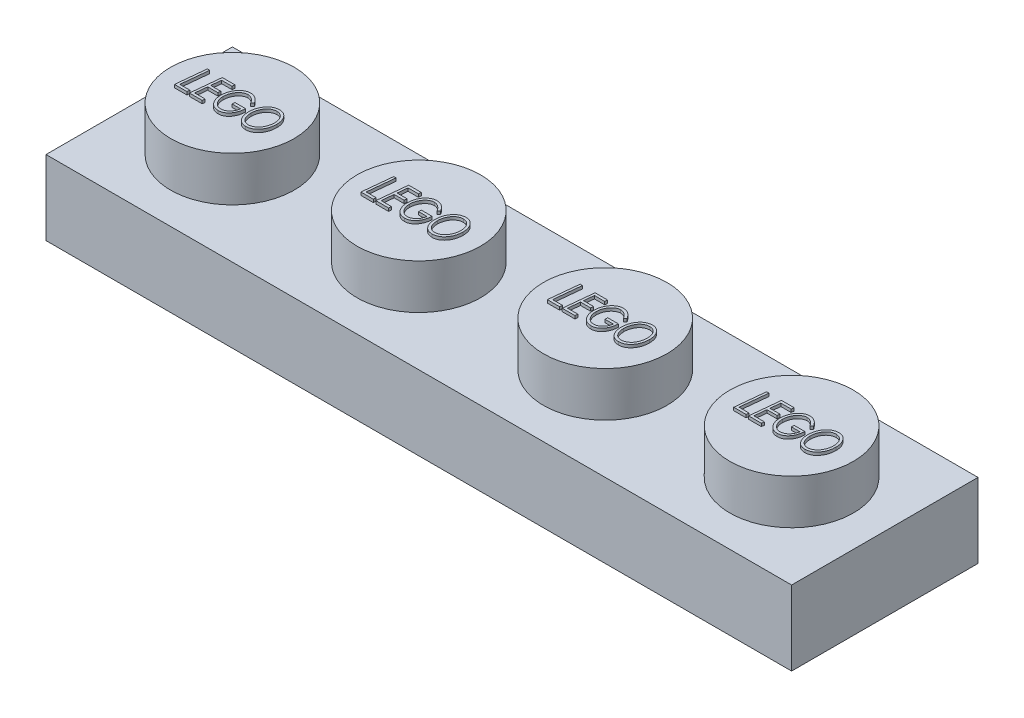
from build123d import *

# Parameters (mm, degrees)
SKETCH2_W           = 31.75
SKETCH2_H           = 7.9375
BOSS_EXTRUDE3_DEPTH = 3.175
SKETCH3_R           = 2.630752939
BOSS_EXTRUDE4_DEPTH = 1.905
LPATTERN1_COUNT     = 4
LPATTERN1_PITCH     = 7.9375
SHELL1_T            = -1.524
BOSS_EXTRUDE5_DEPTH = 0.127
LPATTERN2_COUNT     = 4
LPATTERN2_PITCH     = 7.9375
SKETCH5_R           = 1.4986
SKETCH5_R_2         = 0.635
BOSS_EXTRUDE6_DEPTH = 1.651
LPATTERN3_COUNT     = 3
LPATTERN3_PITCH     = 7.9375


with BuildPart() as part:
    # Sketch2 → Boss-Extrude3 (new body)
    with BuildSketch(Plane(origin=(0, 0, 0), x_dir=(1, 0, 0), z_dir=(0, 1, 0))):
        with Locations((-1.858113381, 4.754641089)):
            Rectangle(SKETCH2_W, SKETCH2_H)
    extrude(amount=BOSS_EXTRUDE3_DEPTH)

    # Sketch3 → Boss-Extrude4 (add)
    with BuildSketch(Plane(origin=(0, 3.175, 0), x_dir=(1, 0, 0), z_dir=(0, 1, 0))):
        with Locations((-13.764363381, 4.754641089)):
            Circle(SKETCH3_R)
    boss_extrude4 = extrude(amount=BOSS_EXTRUDE4_DEPTH)

    # LPattern1: Boss-Extrude4 ×4
    with Locations(*[(i * LPATTERN1_PITCH, 0, 0) for i in range(1, LPATTERN1_COUNT)]):
        add(boss_extrude4)

    # Shell1
    shell1_openings = [part.faces().sort_by_distance(p)[0] for p in [
        (-1.858113381, 0, -4.754641089),
    ]]
    offset(amount=SHELL1_T, openings=shell1_openings, kind=Kind.INTERSECTION)

    # Sketch4 → Boss-Extrude5 (add)
    with BuildSketch(Plane(origin=(0, 5.08, 0), x_dir=(1, 0, 0), z_dir=(0, 1, 0))):
        Polygon((-15.421955913, 5.34660841), (-15.323500384, 5.34660841), (-15.441290849, 4.190582769), (-15.01414141, 4.190582769), (-15.02533532, 4.07660841), (-15.551449102, 4.07660841), align=None)
        Polygon((-14.248885, 5.34660841), (-14.262877387, 5.232634051), (-14.699694294, 5.232634051), (-14.742943493, 4.809300718), (-14.314013205, 4.809300718), (-14.326733557, 4.695326359), (-14.754646217, 4.695326359), (-14.806036442, 4.190582769), (-14.362859359, 4.190582769), (-14.374307676, 4.07660841), (-14.916449102, 4.07660841), (-14.786701506, 5.34660841), align=None)
        with BuildLine():
            Line((-13.157987564, 5.079226599), (-13.23685375, 5.004685333))
            add(Edge.make_bspline(
                [(-13.23685375, 5.004685333), (-13.243036349, 5.014919943), (-13.255215537, 5.03508124), (-13.274843903, 5.0639219), (-13.295404966, 5.090766309), (-13.316668722, 5.115943823), (-13.338681843, 5.139287343), (-13.361588027, 5.160749301), (-13.385450265, 5.180091456), (-13.409701872, 5.197942406), (-13.434658284, 5.213660022), (-13.459747782, 5.227481566), (-13.485177989, 5.238904833), (-13.510565197, 5.248734726), (-13.536282118, 5.256136896), (-13.562187777, 5.261089256), (-13.588089761, 5.264689825), (-13.605477312, 5.265029123), (-13.614139407, 5.265198154)],
                knots=[0, 0, 0, 0, 3.5867e-05, 7.0655e-05, 0.000104594, 0.000137266, 0.00016948, 0.0002008, 0.000231355, 0.000261581, 0.000291084, 0.000319773, 0.000347439, 0.000374655, 0.000401388, 0.000427582, 0.000453742, 0.000479711, 0.000479711, 0.000479711, 0.000479711], degree=3))
            add(Edge.make_bspline(
                [(-13.614139407, 5.265198154), (-13.623817018, 5.264942089), (-13.643246281, 5.264428001), (-13.672242613, 5.260605848), (-13.70083591, 5.253771652), (-13.729278127, 5.244988175), (-13.757272205, 5.233098144), (-13.785048709, 5.218900423), (-13.812373825, 5.20184576), (-13.839460855, 5.182752056), (-13.865426178, 5.16117013), (-13.890266569, 5.13792049), (-13.91359838, 5.112994152), (-13.935710508, 5.086452282), (-13.955872189, 5.057845897), (-13.975112242, 5.027830316), (-13.992587445, 4.995991744), (-14.008566347, 4.962671117), (-14.023015409, 4.928317995), (-14.035508966, 4.893155428), (-14.045942052, 4.857372561), (-14.054589121, 4.820944025), (-14.06149942, 4.783854091), (-14.066312673, 4.746142046), (-14.069143076, 4.707836031), (-14.069568079, 4.682101861), (-14.069782435, 4.669122433)],
                knots=[0, 0, 0, 0, 2.903e-05, 5.8283e-05, 8.7534e-05, 0.000117144, 0.000147477, 0.000178653, 0.000210636, 0.000244026, 0.000278, 0.000311837, 0.000346034, 0.000380367, 0.000415383, 0.000450953, 0.000487277, 0.000524259, 0.000561774, 0.000599029, 0.000636142, 0.000673537, 0.00071131, 0.000749271, 0.000787535, 0.000826472, 0.000826472, 0.000826472, 0.000826472], degree=3))
            add(Edge.make_bspline(
                [(-14.069782435, 4.669122433), (-14.069477418, 4.651721569), (-14.068877636, 4.617504752), (-14.063037479, 4.567164063), (-14.053971473, 4.518756671), (-14.041310983, 4.472223428), (-14.024646127, 4.42784351), (-14.004569657, 4.385349364), (-13.980409537, 4.345047805), (-13.953305264, 4.306998763), (-13.923509762, 4.272231716), (-13.891611692, 4.241833165), (-13.858241554, 4.215836332), (-13.822960448, 4.194859762), (-13.786317389, 4.177985595), (-13.747701019, 4.166780357), (-13.707804487, 4.159194772), (-13.680575585, 4.158413751), (-13.666801666, 4.158018667)],
                knots=[0, 0, 0, 0, 5.2184e-05, 0.000102614, 0.000151811, 0.000199829, 0.000247083, 0.000293853, 0.000340625, 0.000387856, 0.000433855, 0.000477763, 0.000519845, 0.000560465, 0.000600659, 0.0006405, 0.000680822, 0.0007221, 0.0007221, 0.0007221, 0.0007221], degree=3))
            add(Edge.make_bspline(
                [(-13.666801666, 4.158018667), (-13.650119891, 4.158598006), (-13.616764989, 4.159756384), (-13.567583001, 4.170959003), (-13.519199429, 4.187625511), (-13.472815147, 4.211693168), (-13.428975753, 4.24107788), (-13.3888146, 4.275137052), (-13.353443755, 4.314132031), (-13.322014522, 4.35741319), (-13.295472287, 4.406100752), (-13.27204085, 4.459501556), (-13.253441597, 4.518549092), (-13.244174766, 4.559989791), (-13.23939782, 4.581352)],
                knots=[0, 0, 0, 0, 4.9973e-05, 9.9921e-05, 0.000150611, 0.000203177, 0.000256167, 0.000308679, 0.000360721, 0.000413748, 0.000468753, 0.000526746, 0.000588456, 0.000654111, 0.000654111, 0.000654111, 0.000654111], degree=3))
            Line((-13.23939782, 4.581352), (-13.597602948, 4.581352))
            Line((-13.597602948, 4.581352), (-13.597602948, 4.695326359))
            Line((-13.597602948, 4.695326359), (-13.141705512, 4.695326359))
            add(Edge.make_bspline(
                [(-13.141705512, 4.695326359), (-13.143220249, 4.671630935), (-13.14618471, 4.625257073), (-13.156473523, 4.557663764), (-13.169882793, 4.493369383), (-13.188032162, 4.432650411), (-13.210191974, 4.37537214), (-13.236456597, 4.321477624), (-13.266757599, 4.270933421), (-13.300959259, 4.224225256), (-13.338414001, 4.182195788), (-13.37822362, 4.145176879), (-13.420442551, 4.113917018), (-13.464913787, 4.088167818), (-13.511934995, 4.06856876), (-13.561029266, 4.05415967), (-13.612484302, 4.045619356), (-13.647519936, 4.044574047), (-13.665275224, 4.044044308)],
                knots=[0, 0, 0, 0, 7.12e-05, 0.000139344, 0.00020491, 0.000268096, 0.00032923, 0.000388964, 0.000447735, 0.000505793, 0.000562373, 0.000616384, 0.000668589, 0.000719646, 0.000770156, 0.000821037, 0.000872858, 0.000926102, 0.000926102, 0.000926102, 0.000926102], degree=3))
            add(Edge.make_bspline(
                [(-13.665275224, 4.044044308), (-13.683458795, 4.044552296), (-13.719178417, 4.045550182), (-13.771372456, 4.054296421), (-13.821069071, 4.067841152), (-13.868065514, 4.087506656), (-13.912556407, 4.112374207), (-13.953984263, 4.143464588), (-13.993154071, 4.179412869), (-14.029026836, 4.220871562), (-14.061293356, 4.26652386), (-14.090007965, 4.315160597), (-14.113916063, 4.366865748), (-14.133555901, 4.421262957), (-14.148827293, 4.478548833), (-14.159713516, 4.538607223), (-14.166095756, 4.601566492), (-14.167008525, 4.644430286), (-14.167474743, 4.666323955)],
                knots=[0, 0, 0, 0, 5.4515e-05, 0.000107089, 0.00015832, 0.000208732, 0.000259537, 0.000310826, 0.000363759, 0.000418756, 0.000474947, 0.000531277, 0.000587959, 0.00064558, 0.000704576, 0.000765604, 0.000828511, 0.000894188, 0.000894188, 0.000894188, 0.000894188], degree=3))
            add(Edge.make_bspline(
                [(-14.167474743, 4.666323955), (-14.167185589, 4.682101713), (-14.16661133, 4.713436248), (-14.163381594, 4.759994442), (-14.157432775, 4.805749539), (-14.149274332, 4.850644315), (-14.139160769, 4.894945835), (-14.126422318, 4.938327925), (-14.111352878, 4.98094547), (-14.094155797, 5.022494256), (-14.074869439, 5.062577802), (-14.053847868, 5.100800933), (-14.03078607, 5.136684011), (-14.006484206, 5.170754132), (-13.979939226, 5.202226268), (-13.951836475, 5.231556391), (-13.922318071, 5.259016319), (-13.890824475, 5.283795413), (-13.858123028, 5.306042524), (-13.824881044, 5.325834039), (-13.790743443, 5.34211596), (-13.756112763, 5.355771227), (-13.720646944, 5.366079712), (-13.684726153, 5.373904452), (-13.648081628, 5.378221983), (-13.623478046, 5.378854133), (-13.611086522, 5.379172513)],
                knots=[0, 0, 0, 0, 4.7337e-05, 9.4011e-05, 0.000139924, 0.000185684, 0.000230857, 0.000276183, 0.000321242, 0.000366409, 0.000411014, 0.000454628, 0.000497184, 0.000538913, 0.000580086, 0.000620572, 0.000660721, 0.00070093, 0.000740658, 0.000779316, 0.000816866, 0.000854, 0.000890868, 0.000927543, 0.000964179, 0.001001354, 0.001001354, 0.001001354, 0.001001354], degree=3))
            add(Edge.make_bspline(
                [(-13.611086522, 5.379172513), (-13.599885481, 5.378887615), (-13.577690409, 5.378323085), (-13.544759644, 5.375041802), (-13.512580278, 5.369229816), (-13.481226926, 5.36060081), (-13.450309917, 5.350370482), (-13.420236456, 5.337162127), (-13.39072561, 5.322040578), (-13.362124517, 5.304229546), (-13.334002379, 5.284471776), (-13.306931369, 5.261858803), (-13.280001622, 5.237508559), (-13.254169985, 5.210414835), (-13.228831131, 5.181124192), (-13.20464202, 5.149192743), (-13.18043895, 5.115396141), (-13.16557029, 5.091442492), (-13.157987564, 5.079226599)],
                knots=[0, 0, 0, 0, 3.3606e-05, 6.6591e-05, 9.9176e-05, 0.000131574, 0.000164077, 0.000196781, 0.000230006, 0.000263473, 0.000297779, 0.000333024, 0.000369219, 0.000406644, 0.000445248, 0.000485345, 0.000526779, 0.000569901, 0.000569901, 0.000569901, 0.000569901], degree=3))
        make_face()
        with BuildLine():
            add(Edge.make_bspline(
                [(-12.369325705, 5.379172513), (-12.353010143, 5.378720522), (-12.32085994, 5.377829863), (-12.273715249, 5.369659659), (-12.22864765, 5.356507424), (-12.185856311, 5.337650018), (-12.145072326, 5.313842859), (-12.10647493, 5.284550539), (-12.070049375, 5.250024202), (-12.036169842, 5.210647693), (-12.00531375, 5.167406166), (-11.978235129, 5.120902684), (-11.955360597, 5.071642915), (-11.936357429, 5.019696609), (-11.921887955, 4.964835989), (-11.911994605, 4.907187182), (-11.905270318, 4.84685662), (-11.904608097, 4.805673345), (-11.904269615, 4.784623234)],
                knots=[0, 0, 0, 0, 4.8912e-05, 9.6383e-05, 0.000143072, 0.00018944, 0.000236302, 0.000284436, 0.000334467, 0.000386593, 0.000440034, 0.000493616, 0.000547793, 0.000602762, 0.000659349, 0.000717739, 0.000778115, 0.000841241, 0.000841241, 0.000841241, 0.000841241], degree=3))
            add(Edge.make_bspline(
                [(-11.904269615, 4.784623234), (-11.904724813, 4.758992871), (-11.905619371, 4.708623908), (-11.913649979, 4.634691374), (-11.926918957, 4.563951657), (-11.945042207, 4.49615546), (-11.969268607, 4.431731122), (-11.997812291, 4.369990143), (-12.032508136, 4.311855249), (-12.071636526, 4.257287391), (-12.11438555, 4.207292778), (-12.160684455, 4.163785264), (-12.209491268, 4.12681072), (-12.260952984, 4.096525947), (-12.315022525, 4.072933007), (-12.371712054, 4.05602052), (-12.43112154, 4.045889546), (-12.47164277, 4.044665448), (-12.49220431, 4.044044308)],
                knots=[0, 0, 0, 0, 7.6873e-05, 0.000151071, 0.000222773, 0.000292635, 0.000361299, 0.000429016, 0.000496426, 0.000564063, 0.000630262, 0.000693435, 0.00075429, 0.000813586, 0.000872147, 0.000930825, 0.000990675, 0.00105233, 0.00105233, 0.00105233, 0.00105233], degree=3))
            add(Edge.make_bspline(
                [(-12.49220431, 4.044044308), (-12.509616292, 4.04451494), (-12.543682005, 4.04543571), (-12.593480052, 4.053188575), (-12.640452828, 4.066244037), (-12.684989099, 4.084066344), (-12.726670432, 4.107489433), (-12.765818741, 4.135865921), (-12.802122503, 4.169487075), (-12.83534682, 4.207966726), (-12.865201071, 4.250535984), (-12.891189794, 4.296615807), (-12.91347966, 4.345682347), (-12.931507817, 4.398084844), (-12.945433182, 4.453595942), (-12.955221104, 4.512216375), (-12.961524863, 4.573921358), (-12.962237892, 4.616189815), (-12.962602948, 4.637830365)],
                knots=[0, 0, 0, 0, 5.2215e-05, 0.000102157, 0.000150733, 0.000198212, 0.000245705, 0.000293794, 0.000342944, 0.000393802, 0.000446031, 0.000498666, 0.000552293, 0.000607486, 0.000664684, 0.000723782, 0.000785651, 0.000850556, 0.000850556, 0.000850556, 0.000850556], degree=3))
            add(Edge.make_bspline(
                [(-12.962602948, 4.637830365), (-12.962348656, 4.654713021), (-12.961844621, 4.68817633), (-12.958119133, 4.737832996), (-12.952514622, 4.786550271), (-12.943616351, 4.83402181), (-12.933066316, 4.8806248), (-12.919782503, 4.926031082), (-12.904304725, 4.970508016), (-12.88616901, 5.013561667), (-12.866377445, 5.055186009), (-12.843997862, 5.094446642), (-12.820275911, 5.131646309), (-12.79433308, 5.166341896), (-12.767012283, 5.199072462), (-12.737321482, 5.229081319), (-12.705989763, 5.256911788), (-12.672917443, 5.282323432), (-12.638580562, 5.305193307), (-12.602929741, 5.324828759), (-12.566454338, 5.341794401), (-12.528918438, 5.355489869), (-12.490336002, 5.365956739), (-12.450894272, 5.373598515), (-12.410399159, 5.378302894), (-12.383076102, 5.378881385), (-12.369325705, 5.379172513)],
                knots=[0, 0, 0, 0, 5.0643e-05, 0.00010038, 0.000149323, 0.000197677, 0.000245196, 0.000292617, 0.000339526, 0.000386395, 0.000432706, 0.000477705, 0.000521881, 0.000564978, 0.000607585, 0.000649681, 0.000691492, 0.000733218, 0.000774708, 0.000815134, 0.000855202, 0.000895282, 0.000934843, 0.000975008, 0.001015717, 0.001056959, 0.001056959, 0.001056959, 0.001056959], degree=3))
        make_face()
        with BuildLine():
            add(Edge.make_bspline(
                [(-12.37059774, 5.265198154), (-12.382313596, 5.264974538), (-12.405384953, 5.264534185), (-12.43952799, 5.260405022), (-12.472806234, 5.254641281), (-12.50500305, 5.2453884), (-12.53641925, 5.23449868), (-12.566541003, 5.220073421), (-12.596086752, 5.204049224), (-12.624325369, 5.185085614), (-12.651275466, 5.163901314), (-12.677105719, 5.1407675), (-12.701242778, 5.115240955), (-12.723914887, 5.087622005), (-12.745319033, 5.058107871), (-12.765258418, 5.02643651), (-12.783453767, 4.992497975), (-12.800435903, 4.956872571), (-12.815618513, 4.919838387), (-12.828923446, 4.882001808), (-12.839728639, 4.843441788), (-12.848995625, 4.804516904), (-12.856130352, 4.764939705), (-12.861169544, 4.724771762), (-12.864339072, 4.683929196), (-12.8647191, 4.656492627), (-12.864910641, 4.642664099)],
                knots=[0, 0, 0, 0, 3.5131e-05, 6.9182e-05, 0.000103064, 0.000136333, 0.000169567, 0.000202688, 0.000236393, 0.000270332, 0.000304582, 0.000339169, 0.000374259, 0.000409863, 0.000446299, 0.000483568, 0.000522044, 0.000561759, 0.000601917, 0.000642065, 0.000682008, 0.000721995, 0.000762067, 0.000802584, 0.000843403, 0.000884884, 0.000884884, 0.000884884, 0.000884884], degree=3))
            add(Edge.make_bspline(
                [(-12.864910641, 4.642664099), (-12.864307988, 4.619656102), (-12.863131603, 4.574744224), (-12.854429419, 4.509171597), (-12.839695903, 4.447271889), (-12.822395219, 4.398577377), (-12.806018379, 4.361918699), (-12.792619836, 4.336186177), (-12.777779937, 4.312362342), (-12.762246178, 4.289966829), (-12.745390246, 4.269317365), (-12.727389498, 4.250238819), (-12.708171153, 4.232904881), (-12.688073445, 4.216982903), (-12.666766853, 4.20305699), (-12.644505145, 4.191085763), (-12.621414016, 4.180768501), (-12.597334266, 4.172401088), (-12.572284701, 4.166087649), (-12.546442494, 4.161495703), (-12.519659259, 4.158635539), (-12.50145487, 4.158226513), (-12.49220431, 4.158018667)],
                knots=[0, 0, 0, 0, 6.9012e-05, 0.000134712, 0.000198022, 0.000259579, 0.000289414, 0.000318432, 0.000346532, 0.000373564, 0.000400145, 0.00042642, 0.000452175, 0.000477724, 0.000503267, 0.000528424, 0.00055348, 0.000579065, 0.000604796, 0.000630896, 0.000657755, 0.000685504, 0.000685504, 0.000685504, 0.000685504], degree=3))
            add(Edge.make_bspline(
                [(-12.49220431, 4.158018667), (-12.481164543, 4.158226379), (-12.45926255, 4.158638462), (-12.426815915, 4.163069526), (-12.394912776, 4.169171543), (-12.363753517, 4.178557501), (-12.333054523, 4.1901992), (-12.30315314, 4.204836709), (-12.27362727, 4.221656145), (-12.245054493, 4.241259996), (-12.217396148, 4.263059149), (-12.191102552, 4.2869402), (-12.166751424, 4.31313992), (-12.143343282, 4.340857537), (-12.121926482, 4.370957713), (-12.101553921, 4.402800133), (-12.083509498, 4.437043875), (-12.066362584, 4.472756352), (-12.051268705, 4.510002211), (-12.037904005, 4.548157353), (-12.027111895, 4.587233797), (-12.017881689, 4.626845971), (-12.010718503, 4.667266057), (-12.005706916, 4.708370092), (-12.002526277, 4.750312827), (-12.002151397, 4.778511748), (-12.001961923, 4.79276426)],
                knots=[0, 0, 0, 0, 3.3097e-05, 6.5662e-05, 9.8093e-05, 0.000130454, 0.000163149, 0.000196488, 0.000230221, 0.000265008, 0.000300331, 0.000335806, 0.000371442, 0.000407566, 0.000444563, 0.000482183, 0.000520883, 0.000560598, 0.000600991, 0.00064138, 0.000681813, 0.000722543, 0.000763366, 0.000804893, 0.000846727, 0.000889479, 0.000889479, 0.000889479, 0.000889479], degree=3))
            add(Edge.make_bspline(
                [(-12.001961923, 4.79276426), (-12.002383429, 4.811264), (-12.003207157, 4.847417056), (-12.008729979, 4.900202516), (-12.018384404, 4.949996074), (-12.031884335, 4.996843587), (-12.049147304, 5.040781654), (-12.070413266, 5.081809748), (-12.095511146, 5.119934561), (-12.115257706, 5.142857206), (-12.125094935, 5.15427668)],
                knots=[0, 0, 0, 0, 5.5498e-05, 0.000108457, 0.000158999, 0.000207469, 0.000254523, 0.000300379, 0.00034589, 0.00039107, 0.00039107, 0.00039107, 0.00039107], degree=3))
            add(Edge.make_bspline(
                [(-12.125094935, 5.15427668), (-12.133669324, 5.163096064), (-12.150521626, 5.180429887), (-12.178137379, 5.203115094), (-12.206989058, 5.222389045), (-12.237249627, 5.237947562), (-12.268734009, 5.250365639), (-12.301624315, 5.258916547), (-12.335745739, 5.264150728), (-12.358876291, 5.264845883), (-12.37059774, 5.265198154)],
                knots=[0, 0, 0, 0, 3.6878e-05, 7.2482e-05, 0.000106986, 0.00014078, 0.00017437, 0.000208309, 0.000242526, 0.000277679, 0.000277679, 0.000277679, 0.000277679], degree=3))
        make_face(mode=Mode.SUBTRACT)
    boss_extrude5 = extrude(amount=BOSS_EXTRUDE5_DEPTH)

    # LPattern2: Boss-Extrude5 ×4
    with Locations(*[(i * LPATTERN2_PITCH, 0, 0) for i in range(1, LPATTERN2_COUNT)]):
        add(boss_extrude5)

    # Sketch5 → Boss-Extrude6 (add)
    with BuildSketch(Plane.XZ):
        with Locations((-9.795613381, -4.754641089)):
            Circle(SKETCH5_R)
        with Locations((-9.795613381, -4.754641089)):
            Circle(SKETCH5_R_2, mode=Mode.SUBTRACT)
    boss_extrude6 = extrude(amount=-BOSS_EXTRUDE6_DEPTH)

    # LPattern3: Boss-Extrude6 ×3
    with Locations(*[(i * LPATTERN3_PITCH, 0, 0) for i in range(1, LPATTERN3_COUNT)]):
        add(boss_extrude6)


solid = part.part
